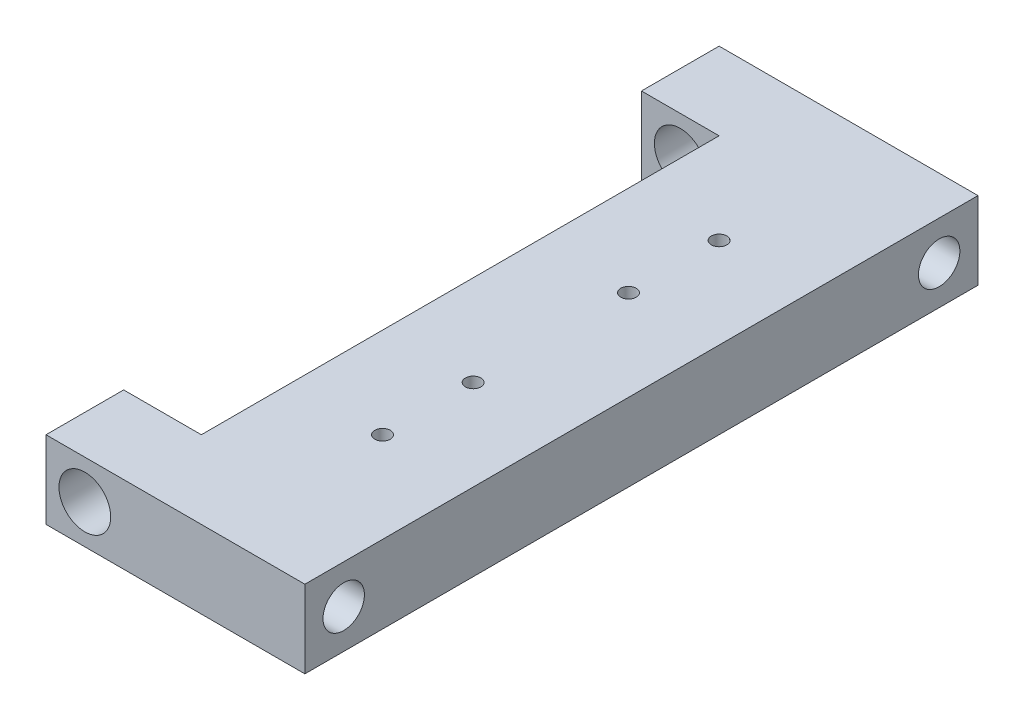
from build123d import *

# Parameters (mm, degrees)
ESQUISSE1_W             = 15
ESQUISSE1_H             = 15
ESQUISSE1_R             = 5
ESQUISSE1_W_2           = 35
BOSS_EXTRU_1_DEPTH      = 130
ESQUISSE2_W             = 15
ESQUISSE2_H             = 100
ENL_V_MAT_EXTRU_1_DEPTH = 60
ESQUISSE3_R             = 4
ENL_V_MAT_EXTRU_2_DEPTH = 35
ESQUISSE4_R             = 1.5
ENL_V_MAT_EXTRU_3_DEPTH = 5
ESQUISSE5_R             = 1.5
ENL_V_MAT_EXTRU_4_DEPTH = 15


with BuildPart() as part:
    # Esquisse1 → Boss.-Extru.1 (new body)
    with BuildSketch(Plane.XY):
        Rectangle(ESQUISSE1_W, ESQUISSE1_H)
        Circle(ESQUISSE1_R, mode=Mode.SUBTRACT)
        with Locations((25, 0)):
            Rectangle(ESQUISSE1_W_2, ESQUISSE1_H)
    extrude(amount=BOSS_EXTRU_1_DEPTH)

    # Esquisse2 → Enlèv. mat.-Extru.1 (cut)
    with BuildSketch(Plane(origin=(0, 7.5, 0), x_dir=(1, 0, 0), z_dir=(0, 1, 0))):
        with Locations((0, -65)):
            Rectangle(ESQUISSE2_W, ESQUISSE2_H)
    extrude(amount=-ENL_V_MAT_EXTRU_1_DEPTH, mode=Mode.SUBTRACT)

    # Esquisse3 → Enlèv. mat.-Extru.2 (cut)
    with BuildSketch(Plane(origin=(42.5, 0, 0), x_dir=(0, 0, -1), z_dir=(1, 0, 0))):
        with Locations((-122.5, 0)):
            Circle(ESQUISSE3_R)
        with Locations((-7.5, 0)):
            Circle(ESQUISSE3_R)
    extrude(amount=-ENL_V_MAT_EXTRU_2_DEPTH, mode=Mode.SUBTRACT)

    # Esquisse4 → Enlèv. mat.-Extru.3 (cut)
    with BuildSketch(Plane(origin=(0, 7.5, 0), x_dir=(1, 0, 0), z_dir=(0, 1, 0))):
        with Locations((25, -32.5)):
            Circle(ESQUISSE4_R)
        with Locations((25, -97.5)):
            Circle(ESQUISSE4_R)
    extrude(amount=-ENL_V_MAT_EXTRU_3_DEPTH, mode=Mode.SUBTRACT)

    # Esquisse5 → Enlèv. mat.-Extru.4 (cut)
    with BuildSketch(Plane(origin=(0, 7.5, 0), x_dir=(1, 0, 0), z_dir=(0, 1, 0))):
        with Locations((25, -50)):
            Circle(ESQUISSE5_R)
        with Locations((25, -80)):
            Circle(ESQUISSE5_R)
    extrude(amount=-ENL_V_MAT_EXTRU_4_DEPTH, mode=Mode.SUBTRACT)


solid = part.part
